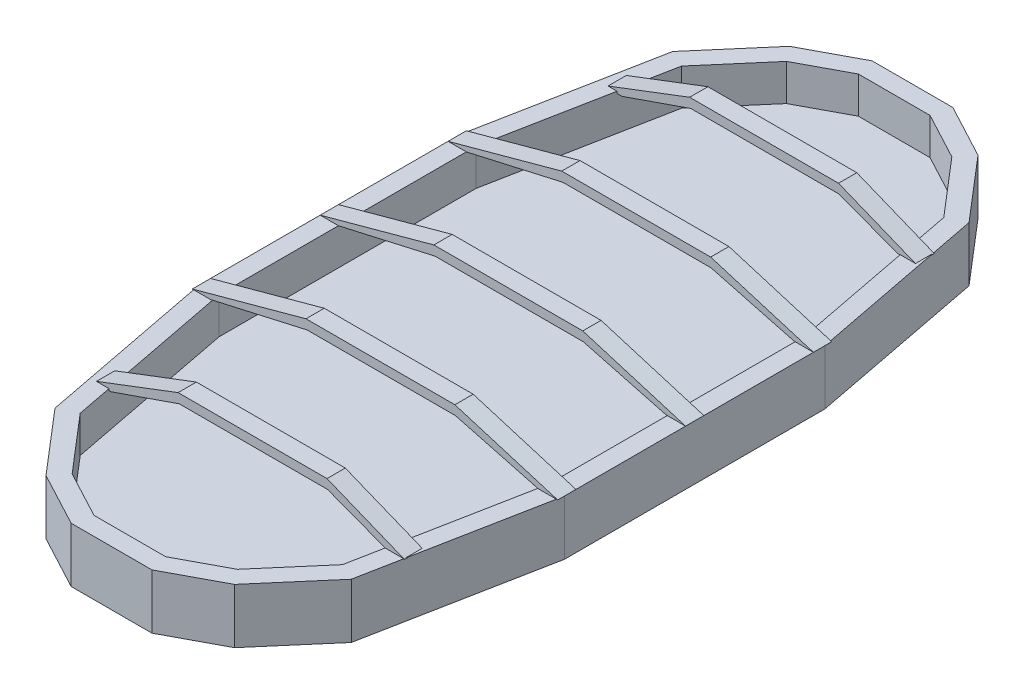
from build123d import *

# Parameters (mm, degrees)
BOSS_EXTRUDE1_DEPTH      = 30
SHELL1_T                 = -10
BOSS_EXTRUDE2_DEPTH      = 5
BOSS_EXTRUDE2_DEPTH_BACK = 5
BOSS_EXTRUDE3_DEPTH      = 5
BOSS_EXTRUDE3_DEPTH_BACK = 5
BOSS_EXTRUDE4_DEPTH      = 5
BOSS_EXTRUDE4_DEPTH_BACK = 5
BOSS_EXTRUDE5_DEPTH      = 5
BOSS_EXTRUDE5_DEPTH_BACK = 5
BOSS_EXTRUDE6_DEPTH      = 5
BOSS_EXTRUDE6_DEPTH_BACK = 5


with BuildPart() as part:
    # Sketch1 → Boss-Extrude1 (new body)
    with BuildSketch(Plane(origin=(0, 0, 0), x_dir=(1, 0, 0), z_dir=(0, 1, 0))):
        Polygon((-100, -71.262798635), (-100, 71.262798635), (-81.092150171, 169.064846416), (-51.604095563, 203.467576792), (-22.116040956, 219.194539249), (-2.218430034, 219.194539249), (2.218430034, 219.194539249), (22.116040956, 219.194539249), (51.604095563, 203.467576792), (81.092150171, 169.064846416), (100, 71.262798635), (100, -71.262798635), (81.092150171, -169.064846416), (51.604095563, -203.467576792), (22.116040956, -219.194539249), (2.218430034, -219.194539249), (-2.218430034, -219.194539249), (-22.116040956, -219.194539249), (-51.604095563, -203.467576792), (-81.092150171, -169.064846416), align=None)
    extrude(amount=BOSS_EXTRUDE1_DEPTH)

    # Shell1
    shell1_openings = [part.faces().sort_by_distance(p)[0] for p in [
        (0, 30, 0),
    ]]
    offset(amount=SHELL1_T, openings=shell1_openings, kind=Kind.INTERSECTION)

    # Sketch8 → Boss-Extrude2 (add, two sides)
    with BuildSketch(Plane.XY.offset(140)) as boss_extrude2_sk:
        Polygon((-85.23886946, 28.936642873), (-37.764332208, 47), (43.730401993, 46.992588144), (86.132065283, 29.884377125), (76.005879539, 29.884377125), (44.002548329, 42), (-37.120930368, 42), (-74.777956797, 28.936642873), align=None)
    extrude(amount=BOSS_EXTRUDE2_DEPTH)
    extrude(boss_extrude2_sk.sketch, amount=-BOSS_EXTRUDE2_DEPTH_BACK)

    # Sketch4 → Boss-Extrude3 (add, two sides)
    with BuildSketch(Plane.XY.offset(70)) as boss_extrude3_sk:
        Polygon((-100, 30), (-37.764332208, 47), (43.730401993, 46.992588144), (100, 30), (89.335605337, 30), (44.002548329, 42), (-37.120930368, 42), (-90, 30), align=None)
    extrude(amount=BOSS_EXTRUDE3_DEPTH)
    extrude(boss_extrude3_sk.sketch, amount=-BOSS_EXTRUDE3_DEPTH_BACK)

    # Sketch5 → Boss-Extrude4 (add, two sides)
    with BuildSketch(Plane.XY.offset(-70)) as boss_extrude4_sk:
        Polygon((-100, 30), (-37.764332208, 47), (43.730401993, 46.992588144), (100, 30), (89.335605337, 30), (44.002548329, 42), (-37.120930368, 42), (-90, 30), align=None)
    extrude(amount=BOSS_EXTRUDE4_DEPTH)
    extrude(boss_extrude4_sk.sketch, amount=-BOSS_EXTRUDE4_DEPTH_BACK)

    # Sketch7 → Boss-Extrude5 (add, two sides)
    with BuildSketch(Plane.XY.offset(-140)) as boss_extrude5_sk:
        Polygon((86.132065283, 29.884377125), (43.730401993, 46.992588144), (-37.764332208, 47), (-85.23886946, 28.936642873), (-74.777956797, 28.936642873), (-37.120930368, 42), (44.002548329, 42), (76.005879539, 29.884377125), align=None)
    extrude(amount=BOSS_EXTRUDE5_DEPTH)
    extrude(boss_extrude5_sk.sketch, amount=-BOSS_EXTRUDE5_DEPTH_BACK)

    # Sketch2 → Boss-Extrude6 (add, two sides)
    with BuildSketch(Plane.XY) as boss_extrude6_sk:
        Polygon((43.730401993, 46.992588144), (100, 30), (89.335605337, 30), (44.002548329, 42), (-37.120930368, 42), (-90, 30), (-100, 30), (-37.764332208, 47), align=None)
    extrude(amount=BOSS_EXTRUDE6_DEPTH)
    extrude(boss_extrude6_sk.sketch, amount=-BOSS_EXTRUDE6_DEPTH_BACK)


solid = part.part
